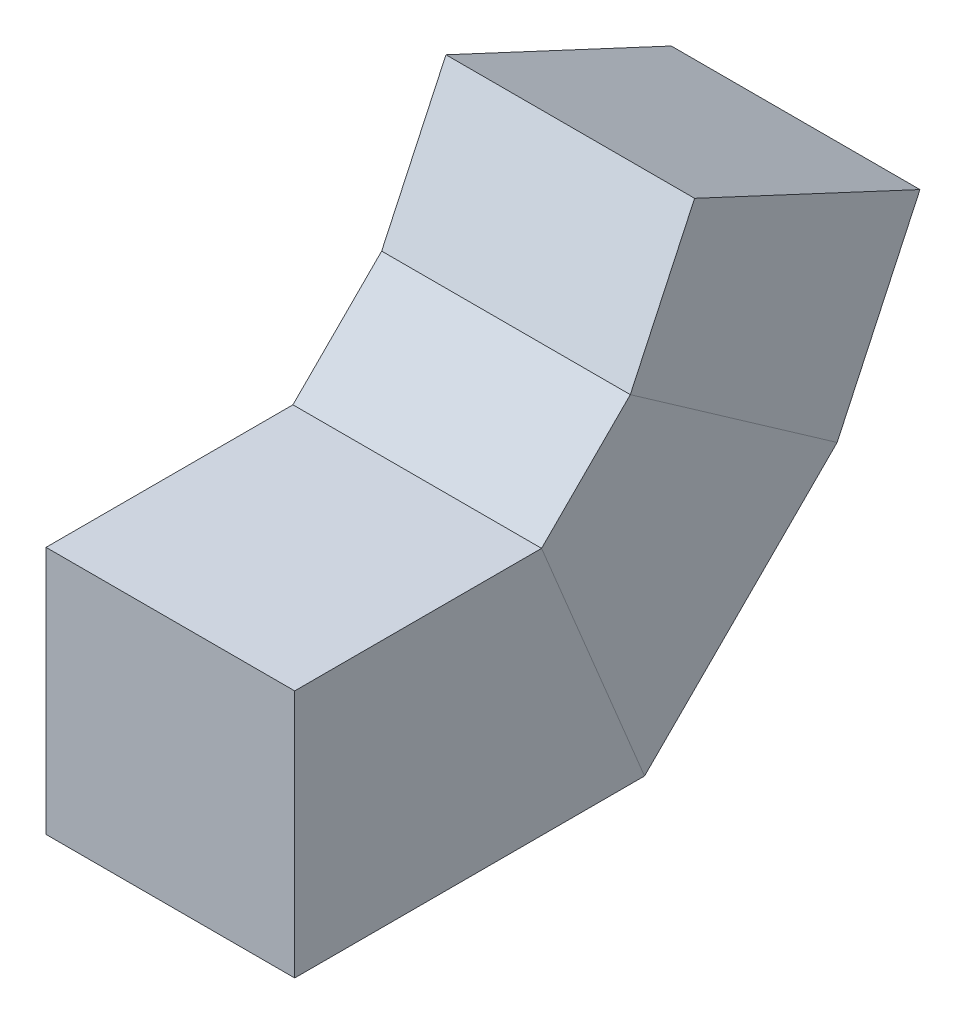
from build123d import *

# Parameters (mm, degrees)
SKETCH1_W = 100
SKETCH1_H = 100


with BuildPart() as part:
    # Sweep1: sweep along a path in Sketch3
    with BuildLine(Plane(origin=(0, 0, 0), x_dir=(0, 0, -1), z_dir=(1, 0, 0))) as sweep1_path:
        Line((0, 0), (120, 0))
        Line((120, 0), (176.568542495, 56.568542495))
        Line((176.568542495, 56.568542495), (206.151820817, 120.010087587))
    # Sketch1 → Sweep1 (sweep)
    with BuildSketch(Plane.XY):
        Rectangle(SKETCH1_W, SKETCH1_H)
    sweep(path=sweep1_path.line, transition=Transition.RIGHT)


solid = part.part
